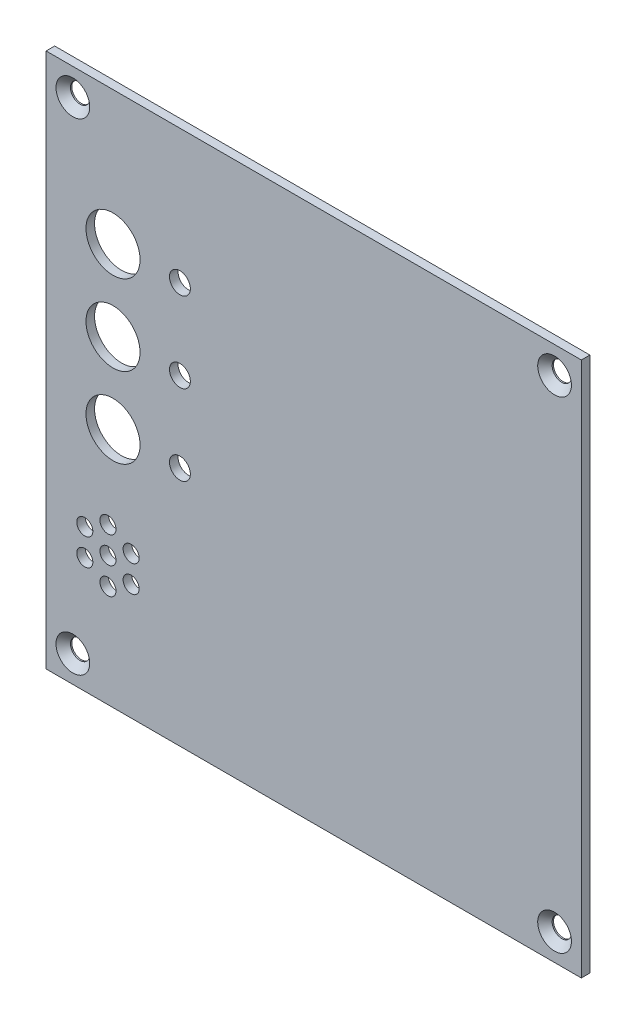
from build123d import *

# Parameters (mm, degrees)
ESQUISSE1_W                                 = 100
ESQUISSE1_H                                 = 100
BOSS_EXTRU_1_DEPTH                          = 1.6
FRAISAGE_POUR_VIS_T_TE_FRAIS_E_M31_AT_COUNT = 2
FRAISAGE_POUR_VIS_T_TE_FRAIS_E_M31_AT_PITCH = 90
FRAISAGE_POUR_VIS_T_TE_FRAIS_E_M31_2_COUNT  = 2
FRAISAGE_POUR_VIS_T_TE_FRAIS_E_M31_2_PITCH  = 127.279220614
FRAISAGE_POUR_VIS_T_TE_FRAIS_E_M31_3_COUNT  = 2
FRAISAGE_POUR_VIS_T_TE_FRAIS_E_M31_3_PITCH  = 90
ESQUISSE4_R                                 = 1.5
ESQUISSE4_R_2                               = 5.05
ESQUISSE4_R_3                               = 1.95
ENL_V_MAT_EXTRU_1_DEPTH                     = 2.6


with BuildPart() as part:
    # Esquisse1 → Boss.-Extru.1 (new body)
    with BuildSketch(Plane.XY):
        with Locations((50, 50)):
            Rectangle(ESQUISSE1_W, ESQUISSE1_H)
    extrude(amount=BOSS_EXTRU_1_DEPTH)

    # Esquisse3 → Fraisage pour vis à tête fraisée M31 (revolve, cut)
    with BuildSketch(Plane(origin=(5, 95, 1.6), x_dir=(0, -1, 0), z_dir=(1, 0, 0))):
        Polygon((0, 0), (0, 1.6), (1.8, 1.6), (1.8, 1.35), (3.15, 0), align=None)
    fraisage_pour_vis_t_te_frais_e_m31 = revolve(axis=Axis((5, 95, 7.95), (0, 0, -1)), mode=Mode.SUBTRACT)

    # Fraisage pour vis à tête fraisée M31 at: Fraisage pour vis à tête fraisée M31 ×2
    with Locations(*[(i * FRAISAGE_POUR_VIS_T_TE_FRAIS_E_M31_AT_PITCH, 0, 0) for i in range(1, FRAISAGE_POUR_VIS_T_TE_FRAIS_E_M31_AT_COUNT)]):
        add(fraisage_pour_vis_t_te_frais_e_m31, mode=Mode.SUBTRACT)

    # Fraisage pour vis _ t_te frais_e M31 2: Fraisage pour vis à tête fraisée M31 ×2
    with Locations(*[Vector(0.707106781, -0.707106781, 0) * (i * FRAISAGE_POUR_VIS_T_TE_FRAIS_E_M31_2_PITCH) for i in range(1, FRAISAGE_POUR_VIS_T_TE_FRAIS_E_M31_2_COUNT)]):
        add(fraisage_pour_vis_t_te_frais_e_m31, mode=Mode.SUBTRACT)

    # Fraisage pour vis _ t_te frais_e M31 3: Fraisage pour vis à tête fraisée M31 ×2
    with Locations(*[(0, -i * FRAISAGE_POUR_VIS_T_TE_FRAIS_E_M31_3_PITCH, 0) for i in range(1, FRAISAGE_POUR_VIS_T_TE_FRAIS_E_M31_3_COUNT)]):
        add(fraisage_pour_vis_t_te_frais_e_m31, mode=Mode.SUBTRACT)

    # Esquisse4 → Enlèv. mat.-Extru.1 (cut, through all)
    with BuildSketch(Plane.XY.offset(1.6)):
        with Locations((11.557, 24.13)):
            Circle(ESQUISSE4_R)
        with Locations((11.557, 29.13)):
            Circle(ESQUISSE4_R)
        with Locations((15.887127019, 26.63)):
            Circle(ESQUISSE4_R)
        with Locations((15.887127019, 21.63)):
            Circle(ESQUISSE4_R)
        with Locations((11.557, 19.13)):
            Circle(ESQUISSE4_R)
        with Locations((7.226872981, 21.63)):
            Circle(ESQUISSE4_R)
        with Locations((7.226872981, 26.63)):
            Circle(ESQUISSE4_R)
        with Locations((12.5, 75)):
            Circle(ESQUISSE4_R_2)
        with Locations((12.5, 60)):
            Circle(ESQUISSE4_R_2)
        with Locations((12.5, 45)):
            Circle(ESQUISSE4_R_2)
        with Locations((25, 75)):
            Circle(ESQUISSE4_R_3)
        with Locations((25, 60)):
            Circle(ESQUISSE4_R_3)
        with Locations((25, 45)):
            Circle(ESQUISSE4_R_3)
    extrude(amount=-ENL_V_MAT_EXTRU_1_DEPTH, mode=Mode.SUBTRACT)


solid = part.part
